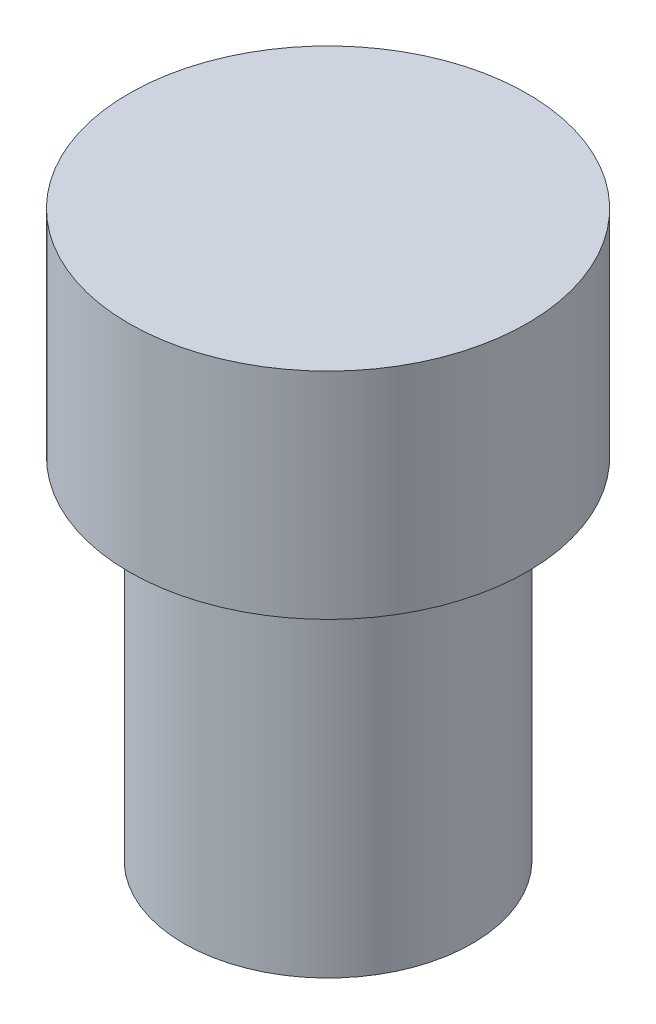
from build123d import *

# Parameters (mm, degrees)
SKETCH2_R           = 32.184938318
BOSS_EXTRUDE1_DEPTH = 78
SKETCH3_R           = 44.452761075
BOSS_EXTRUDE2_DEPTH = 48


with BuildPart() as part:
    # Sketch2 → Boss-Extrude1 (new body)
    with BuildSketch(Plane(origin=(0, 0, 0), x_dir=(1, 0, 0), z_dir=(0, 1, 0))):
        Circle(SKETCH2_R)
    extrude(amount=BOSS_EXTRUDE1_DEPTH)

    # Sketch3 → Boss-Extrude2 (add)
    with BuildSketch(Plane(origin=(0, 78, 0), x_dir=(1, 0, 0), z_dir=(0, 1, 0))):
        Circle(SKETCH3_R)
    extrude(amount=BOSS_EXTRUDE2_DEPTH)


solid = part.part
